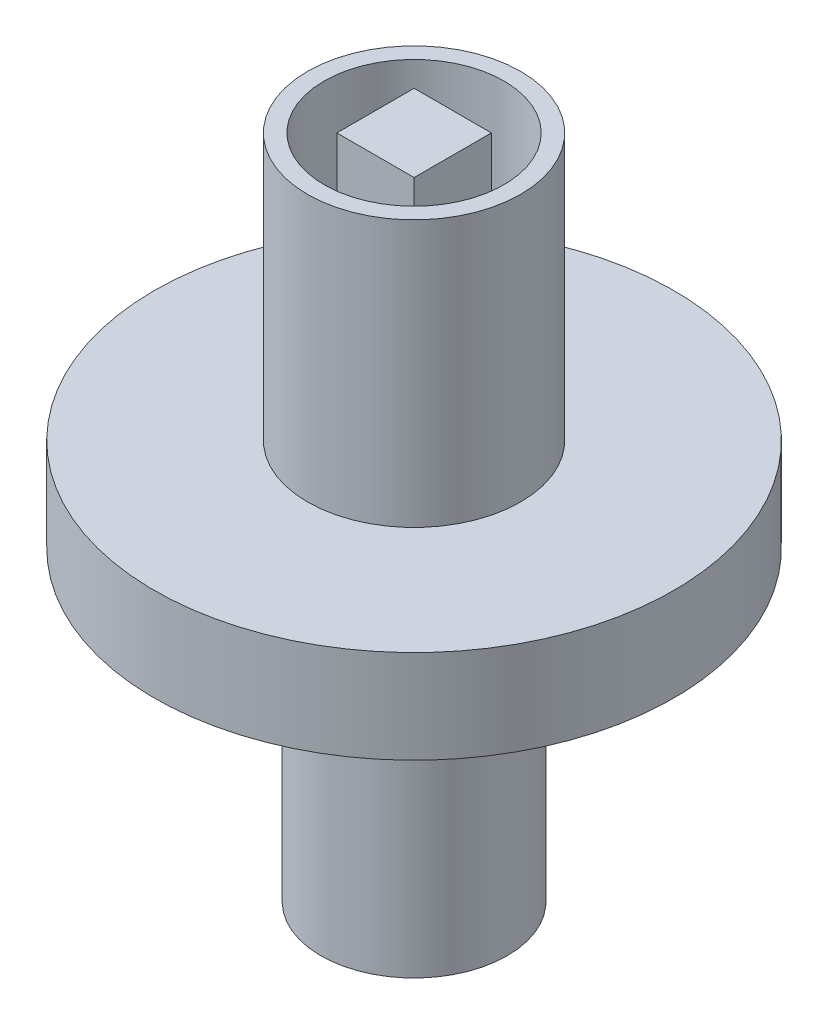
from build123d import *

# Parameters (mm, degrees)
SKETCH3_R           = 6.75
CUT_EXTRUDE1_DEPTH  = 15
SKETCH4_W           = 5.8
SKETCH4_H           = 5.8
BOSS_EXTRUDE1_DEPTH = 15
SKETCH6_R           = 7
BOSS_EXTRUDE2_DEPTH = 23
SKETCH7_R           = 3.5
CUT_EXTRUDE2_DEPTH  = 15
CUT_EXTRUDE3_DEPTH  = 15


with BuildPart() as part:
    # Sketch2 → Revolve2 (revolve)
    with BuildSketch(Plane.XY):
        Polygon((19.5, 0), (19.5, 7), (8, 7), (8, 27), (0, 27), (0, 0), align=None)
    revolve(axis=Axis((0, 96.27972973, 0), (0, -1, 0)))

    # Sketch3 → Cut-Extrude1 (cut)
    with BuildSketch(Plane(origin=(0, 27, 0), x_dir=(1, 0, 0), z_dir=(0, 1, 0))):
        Circle(SKETCH3_R)
    extrude(amount=-CUT_EXTRUDE1_DEPTH, mode=Mode.SUBTRACT)

    # Sketch4 → Boss-Extrude1 (add)
    with BuildSketch(Plane(origin=(0, 12, 0), x_dir=(1, 0, 0), z_dir=(0, 1, 0))):
        with Locations((0.004761868, -0.002625461)):
            Rectangle(SKETCH4_W, SKETCH4_H)
    extrude(amount=BOSS_EXTRUDE1_DEPTH)

    # Sketch6 → Boss-Extrude2 (add)
    with BuildSketch(Plane.XZ):
        Circle(SKETCH6_R)
    extrude(amount=BOSS_EXTRUDE2_DEPTH)

    # Sketch7 → Cut-Extrude2 (cut)
    with BuildSketch(Plane.XZ.offset(23)):
        Circle(SKETCH7_R)
    extrude(amount=-CUT_EXTRUDE2_DEPTH, mode=Mode.SUBTRACT)

    # Sketch8 → Cut-Extrude3 (cut)
    with BuildSketch(Plane.XZ.offset(23)):
        Polygon((-5.3, 1.5), (-1.5, 1.5), (-1.5, 5.3), (1.5, 5.3), (1.5, 1.5), (5.3, 1.5), (5.3, -1.5), (1.5, -1.5), (1.5, -5.3), (-1.5, -5.3), (-1.5, -1.5), (-5.3, -1.5), align=None)
    extrude(amount=-CUT_EXTRUDE3_DEPTH, mode=Mode.SUBTRACT)


solid = part.part
